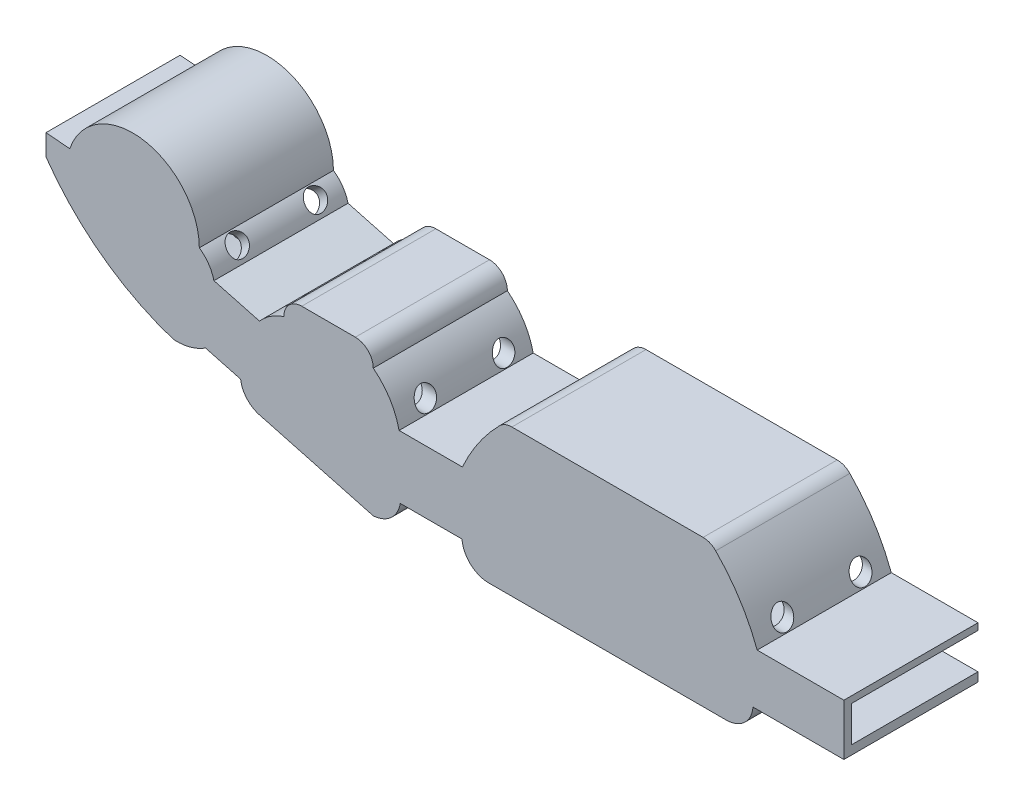
from build123d import *

# Parameters (mm, degrees)
WALLS_DEPTH                         = 16
BASE_DEPTH                          = 1
CUT_EXTRUDE2_REACH                  = 71.681
CUT_EXTRUDE2_END_RADIUS             = 7.978898039
SKETCH14_R                          = 1.4
CUT_EXTRUDE3_REACH                  = 103.113
CUT_EXTRUDE3_END_RADIUS             = 7.978898039
SKETCH15_R                          = 1.4
CUT_EXTRUDE4_REACH                  = 83.005
CUT_EXTRUDE4_END_RADIUS             = 33.443931457
SKETCH16_R                          = 1.4
CUT_EXTRUDE4_DIRECTION_2_REACH      = 83.005
CUT_EXTRUDE4_DIRECTION_2_END_RADIUS = 4.849339701
CUT_EXTRUDE5_REACH                  = 82.538
CUT_EXTRUDE5_END_RADIUS             = 6.135740623
SKETCH18_R                          = 1.4
CUT_EXTRUDE6_DEPTH                  = 1
CUT_EXTRUDE7_START                  = 4
SKETCH20_W                          = 0.5
SKETCH20_H                          = 5.968950485
CUT_EXTRUDE7_DEPTH                  = 10
CUT_EXTRUDE8_START                  = -1
SKETCH21_W                          = 1.2
SKETCH21_H                          = 4.8
CUT_EXTRUDE8_DEPTH                  = 17
BOSS_EXTRUDE7_DEPTH                 = 1


with BuildPart() as part:
    # Sketch1 → Walls (new body)
    with BuildSketch(Plane.XY):
        with BuildLine():
            Line((-97.602924667, 15.217392614), (-97.602924667, 12.385824824))
            ThreePointArc((-97.602924667, 12.385824824), (-90.083595642, 4.663063574), (-80.498331365, -0.266851135))
            ThreePointArc((-80.498331365, -0.266851135), (-78.251738027, -0.03182968), (-76.187199333, 0.884738205))
            Line((-76.187199333, 0.884738205), (-73.889967309, 0.268240269))
            Line((-73.889967309, 0.268240269), (-71.482418944, -0.377862773))
            ThreePointArc((-71.482418944, -0.377862773), (-70.590768518, -2.28542285), (-68.756284219, -3.319102342))
            Line((-68.756284219, -3.319102342), (-53.689410768, -7.362532125))
            ThreePointArc((-53.689410768, -7.362532125), (-51.300577468, -6.369383777), (-50.049451725, -4.104973799))
            Line((-50.049451725, -4.104973799), (-41.77845347, -4.104973799))
            ThreePointArc((-41.77845347, -4.104973799), (-40.630797432, -6.460513587), (-38.19022534, -7.414080542))
            Line((-38.19022534, -7.414080542), (-6.302454756, -7.414080542))
            ThreePointArc((-6.302454756, -7.414080542), (-3.861882663, -6.460513587), (-2.714226626, -4.104973799))
            Line((-2.714226626, -4.104973799), (9.481662569, -4.104973799))
            Line((9.481662569, -4.104973799), (9.481662569, 2.795026201))
            Line((9.481662569, 2.795026201), (-2.157765014, 2.795026201))
            ThreePointArc((-2.157765014, 2.795026201), (-4.475421171, 7.467506564), (-7.720187416, 11.551021571))
            ThreePointArc((-7.720187416, 11.551021571), (-8.494484922, 12.081481284), (-9.414311331, 12.268145448))
            Line((-9.414311331, 12.268145448), (-35.074048092, 12.268145448))
            ThreePointArc((-35.074048092, 12.268145448), (-35.993874501, 12.081481284), (-36.768172007, 11.551021571))
            ThreePointArc((-36.768172007, 11.551021571), (-39.567349429, 8.144207478), (-41.718065592, 4.295026201))
            Line((-41.718065592, 4.295026201), (-50.215351143, 4.295026201))
            ThreePointArc((-50.215351143, 4.295026201), (-51.466059783, 7.352239347), (-53.681234518, 9.802509784))
            ThreePointArc((-53.681234518, 9.802509784), (-54.384178243, 11.499566059), (-56.081234518, 12.202509784))
            Line((-56.081234518, 12.202509784), (-63.281234518, 12.202509784))
            ThreePointArc((-63.281234518, 12.202509784), (-64.978290793, 11.499566059), (-65.681234518, 9.802509784))
            ThreePointArc((-65.681234518, 9.802509784), (-67.462133389, 8.942613092), (-68.949921449, 7.63972791))
            Line((-68.949921449, 7.63972791), (-75.062434898, 9.280115945))
            ThreePointArc((-75.062434898, 9.280115945), (-75.782775767, 10.877592909), (-77.023853798, 12.114746473))
            ThreePointArc((-77.023853798, 12.114746473), (-84.520013622, 20.896236037), (-94.41446461, 14.945873803))
            Line((-94.41446461, 14.945873803), (-97.602924667, 15.217392614))
        make_face()
        with BuildLine():
            Line((-35.135188992, 10.657707985), (-34.831931662, 9.152027))
            Line((-34.831931662, 9.152027), (-34.528674333, 10.652027))
            Line((-34.528674333, 10.652027), (-33.854684343, 10.652027))
            Line((-33.854684343, 10.652027), (-33.554684343, 9.152027))
            Line((-33.554684343, 9.152027), (-33.254684343, 10.652027))
            Line((-33.254684343, 10.652027), (-32.554684343, 10.652027))
            Line((-32.554684343, 10.652027), (-32.254684343, 9.152027))
            Line((-32.254684343, 9.152027), (-31.954684343, 10.652027))
            Line((-31.954684343, 10.652027), (-31.254684343, 10.652027))
            Line((-31.254684343, 10.652027), (-30.954684343, 9.152027))
            Line((-30.954684343, 9.152027), (-30.654684343, 10.652027))
            Line((-30.654684343, 10.652027), (-29.954684343, 10.652027))
            Line((-29.954684343, 10.652027), (-29.654684343, 9.152027))
            Line((-29.654684343, 9.152027), (-29.354684343, 10.652027))
            Line((-29.354684343, 10.652027), (-28.654684343, 10.652027))
            Line((-28.654684343, 10.652027), (-28.354684343, 9.152027))
            Line((-28.354684343, 9.152027), (-28.054684343, 10.652027))
            Line((-28.054684343, 10.652027), (-27.354684343, 10.652027))
            Line((-27.354684343, 10.652027), (-27.054684343, 9.152027))
            Line((-27.054684343, 9.152027), (-26.754684343, 10.652027))
            Line((-26.754684343, 10.652027), (-26.054684343, 10.652027))
            Line((-26.054684343, 10.652027), (-25.754684343, 9.152027))
            Line((-25.754684343, 9.152027), (-25.454684343, 10.652027))
            Line((-25.454684343, 10.652027), (-24.754684343, 10.652027))
            Line((-24.754684343, 10.652027), (-24.454684343, 9.152027))
            Line((-24.454684343, 9.152027), (-24.154684343, 10.652027))
            Line((-24.154684343, 10.652027), (-23.454684343, 10.652027))
            Line((-23.454684343, 10.652027), (-23.154684343, 9.152027))
            Line((-23.154684343, 9.152027), (-22.854684343, 10.652027))
            Line((-22.854684343, 10.652027), (-22.154684343, 10.652027))
            Line((-22.154684343, 10.652027), (-21.854684343, 9.152027))
            Line((-21.854684343, 9.152027), (-21.554684343, 10.652027))
            Line((-21.554684343, 10.652027), (-20.854684343, 10.652027))
            Line((-20.854684343, 10.652027), (-20.554684343, 9.152027))
            Line((-20.554684343, 9.152027), (-20.254684343, 10.652027))
            Line((-20.254684343, 10.652027), (-19.554684343, 10.652027))
            Line((-19.554684343, 10.652027), (-19.254684343, 9.152027))
            Line((-19.254684343, 9.152027), (-18.954684343, 10.652027))
            Line((-18.954684343, 10.652027), (-18.254684343, 10.652027))
            Line((-18.254684343, 10.652027), (-17.954684343, 9.152027))
            Line((-17.954684343, 9.152027), (-17.654684343, 10.652027))
            Line((-17.654684343, 10.652027), (-16.954684343, 10.652027))
            Line((-16.954684343, 10.652027), (-16.654684343, 9.152027))
            Line((-16.654684343, 9.152027), (-16.354684343, 10.652027))
            Line((-16.354684343, 10.652027), (-15.654684343, 10.652027))
            Line((-15.654684343, 10.652027), (-15.354684343, 9.152027))
            Line((-15.354684343, 9.152027), (-15.054684343, 10.652027))
            Line((-15.054684343, 10.652027), (-14.354684343, 10.652027))
            Line((-14.354684343, 10.652027), (-14.054684343, 9.152027))
            Line((-14.054684343, 9.152027), (-13.754684343, 10.652027))
            Line((-13.754684343, 10.652027), (-13.080694354, 10.652027))
            Line((-13.080694354, 10.652027), (-12.780694354, 9.152027))
            Line((-12.780694354, 9.152027), (-12.480694354, 10.652027))
            Line((-12.480694354, 10.652027), (-11.780694354, 10.652027))
            Line((-11.780694354, 10.652027), (-11.480694354, 9.152027))
            Line((-11.480694354, 9.152027), (-11.180694354, 10.652027))
            Line((-11.180694354, 10.652027), (-10.506704364, 10.652027))
            Line((-10.506704364, 10.652027), (-10.206704364, 9.152027))
            Line((-10.206704364, 9.152027), (-9.906704364, 10.652027))
            Line((-9.906704364, 10.652027), (-9.353170431, 10.652027))
            ThreePointArc((-9.353170431, 10.652027), (-8.12308073, 9.896738229), (-7.34300907, 8.682213628))
            ThreePointArc((-7.34300907, 8.682213628), (-4.611558125, 5.76795929), (-3.634781843, 1.895026201))
            Line((-3.634781843, 1.895026201), (8.281662569, 1.895026201))
            Line((8.281662569, 1.895026201), (8.281662569, -2.904973799))
            Line((8.281662569, -2.904973799), (-3.718337431, -2.904973799))
            ThreePointArc((-3.718337431, -2.904973799), (-4.489094638, -5.239633694), (-6.746340048, -6.214080542))
            Line((-6.746340048, -6.214080542), (-37.746340048, -6.214080542))
            ThreePointArc((-37.746340048, -6.214080542), (-40.003585457, -5.239633694), (-40.774342664, -2.904973799))
            Line((-40.774342664, -2.904973799), (-51.800725155, -2.904973799))
            ThreePointArc((-51.800725155, -2.904973799), (-52.729784745, -4.937523747), (-54.747520344, -5.898332815))
            Line((-54.747520344, -5.898332815), (-67.30324822, -2.528807996))
            ThreePointArc((-67.30324822, -2.528807996), (-68.974427433, -1.501489359), (-69.597282071, 0.358692257))
            Line((-69.597282071, 0.358692257), (-77.437917333, 2.462848653))
            ThreePointArc((-77.437917333, 2.462848653), (-78.888444716, 1.000283853), (-80.940241825, 0.817926775))
            ThreePointArc((-80.940241825, 0.817926775), (-87.857363605, 4.137190402), (-93.56393849, 9.26545403))
            Line((-93.56393849, 9.26545403), (-96.861437096, 13.209190532))
            Line((-96.861437096, 13.209190532), (-96.861437096, 13.945331795))
            Line((-96.861437096, 13.945331795), (-96.47575976, 13.504674103))
            Line((-96.47575976, 13.504674103), (-94.817997325, 12.385824824))
            ThreePointArc((-94.817997325, 12.385824824), (-94.415427575, 12.562213326), (-94.008614676, 12.728582111))
            ThreePointArc((-94.008614676, 12.728582111), (-93.422599552, 14.777174035), (-92.319028879, 16.599884754))
            Line((-92.319028879, 16.599884754), (-92.019028879, 15.366152694))
            Line((-92.019028879, 15.366152694), (-91.719028879, 17.266152694))
            ThreePointArc((-91.719028879, 17.266152694), (-91.377286671, 17.586290744), (-91.017486201, 17.885990141))
            Line((-91.017486201, 17.885990141), (-90.717486201, 16.813922832))
            Line((-90.717486201, 16.813922832), (-90.417486201, 18.313922832))
            ThreePointArc((-90.417486201, 18.313922832), (-90.073465252, 18.524190844), (-89.719335551, 18.716947696))
            Line((-89.719335551, 18.716947696), (-89.419335551, 17.693779836))
            Line((-89.419335551, 17.693779836), (-89.119335551, 18.993779836))
            ThreePointArc((-89.119335551, 18.993779836), (-88.772503114, 19.127528905), (-88.41985912, 19.245103414))
            Line((-88.41985912, 19.245103414), (-88.11985912, 18.147652874))
            Line((-88.11985912, 18.147652874), (-87.81985912, 19.404765549))
            ThreePointArc((-87.81985912, 19.404765549), (-87.472338401, 19.474995797), (-87.122059311, 19.529836442))
            Line((-87.122059311, 19.529836442), (-86.822059311, 18.396857922))
            Line((-86.822059311, 18.396857922), (-86.522059311, 19.58746676))
            ThreePointArc((-86.522059311, 19.58746676), (-86.171544793, 19.600247924), (-85.82080637, 19.597729108))
            Line((-85.82080637, 19.597729108), (-85.52080637, 18.457829923))
            Line((-85.52080637, 18.457829923), (-85.22080637, 19.557829923))
            ThreePointArc((-85.22080637, 19.557829923), (-84.869658801, 19.513414143), (-84.52080637, 19.453586402))
            Line((-84.52080637, 19.453586402), (-84.22080637, 18.262977563))
            Line((-84.22080637, 18.262977563), (-83.92080637, 19.312977563))
            ThreePointArc((-83.92080637, 19.312977563), (-83.568200749, 19.207208521), (-83.22080637, 19.085409669))
            Line((-83.22080637, 19.085409669), (-82.92080637, 17.831277439))
            Line((-82.92080637, 17.831277439), (-82.62080637, 18.831277439))
            ThreePointArc((-82.62080637, 18.831277439), (-82.2661907, 18.652985458), (-81.92080637, 18.457409466))
            Line((-81.92080637, 18.457409466), (-81.62080637, 16.960277091))
            Line((-81.62080637, 16.960277091), (-81.32080637, 18.060277091))
            ThreePointArc((-81.32080637, 18.060277091), (-80.96274655, 17.783767154), (-80.62080637, 17.487555249))
            Line((-80.62080637, 17.487555249), (-80.32080637, 15.675519278))
            Line((-80.32080637, 15.675519278), (-80.02080637, 16.875519278))
            ThreePointArc((-80.02080637, 16.875519278), (-79.654234956, 16.427873033), (-79.32080637, 15.955023014))
            Line((-79.32080637, 15.955023014), (-79.02080637, 12.857560784))
            Line((-79.02080637, 12.857560784), (-78.72080637, 14.857560784))
            ThreePointArc((-78.72080637, 14.857560784), (-78.159606325, 13.084494169), (-78.02080637, 11.229920016))
            ThreePointArc((-78.02080637, 11.229920016), (-76.848832526, 9.985898204), (-76.295916922, 8.368679203))
            Line((-76.295916922, 8.368679203), (-68.569315152, 6.295125468))
            ThreePointArc((-68.569315152, 6.295125468), (-67.180506607, 7.752660176), (-65.394693914, 8.682213628))
            ThreePointArc((-65.394693914, 8.682213628), (-64.808907476, 10.096427191), (-63.394693914, 10.682213628))
            Line((-63.394693914, 10.682213628), (-63.310840233, 10.682178618))
            Line((-63.310840233, 10.682178618), (-63.010840233, 9.182178618))
            Line((-63.010840233, 9.182178618), (-62.710840233, 10.682178618))
            Line((-62.710840233, 10.682178618), (-62.010840233, 10.682178618))
            Line((-62.010840233, 10.682178618), (-61.710840233, 9.182178618))
            Line((-61.710840233, 9.182178618), (-61.410840233, 10.682178618))
            Line((-61.410840233, 10.682178618), (-60.710840233, 10.682178618))
            Line((-60.710840233, 10.682178618), (-60.410840233, 9.182178618))
            Line((-60.410840233, 9.182178618), (-60.110840233, 10.682178618))
            Line((-60.110840233, 10.682178618), (-59.436850244, 10.682178618))
            Line((-59.436850244, 10.682178618), (-59.136850244, 9.182178618))
            Line((-59.136850244, 9.182178618), (-58.836850244, 10.682178618))
            Line((-58.836850244, 10.682178618), (-58.136850244, 10.682178618))
            Line((-58.136850244, 10.682178618), (-57.836850244, 9.182178618))
            Line((-57.836850244, 9.182178618), (-57.536850244, 10.682178618))
            Line((-57.536850244, 10.682178618), (-57.394693914, 10.682213628))
            ThreePointArc((-57.394693914, 10.682213628), (-55.980480351, 10.096427191), (-55.394693914, 8.682213628))
            ThreePointArc((-55.394693914, 8.682213628), (-52.971538613, 6.284887251), (-51.770022133, 3.095026201))
            Line((-51.770022133, 3.095026201), (-40.770022133, 3.095026201))
            ThreePointArc((-40.770022133, 3.095026201), (-39.568505653, 6.284887251), (-37.145350353, 8.682213628))
            ThreePointArc((-37.145350353, 8.682213628), (-37.020286062, 9.372290059), (-36.66100173, 9.974586769))
            ThreePointArc((-36.66100173, 9.974586769), (-35.973167424, 10.483827589), (-35.135188992, 10.657707985))
        make_face(mode=Mode.SUBTRACT)
    extrude(amount=WALLS_DEPTH)

    # Sketch2 → Base (add)
    with BuildSketch(Plane(origin=(0, 0, 0), x_dir=(-1, 0, 0), z_dir=(0, 0, -1))):
        with BuildLine():
            Line((75.062434898, 9.280115945), (68.949921449, 7.63972791))
            ThreePointArc((68.949921449, 7.63972791), (67.462133389, 8.942613092), (65.681234518, 9.802509784))
            ThreePointArc((65.681234518, 9.802509784), (64.978290793, 11.499566059), (63.281234518, 12.202509784))
            Line((63.281234518, 12.202509784), (56.081234518, 12.202509784))
            ThreePointArc((56.081234518, 12.202509784), (54.384178243, 11.499566059), (53.681234518, 9.802509784))
            ThreePointArc((53.681234518, 9.802509784), (51.466059783, 7.352239347), (50.215351143, 4.295026201))
            Line((50.215351143, 4.295026201), (41.718065592, 4.295026201))
            ThreePointArc((41.718065592, 4.295026201), (39.567349429, 8.144207478), (36.768172007, 11.551021571))
            ThreePointArc((36.768172007, 11.551021571), (35.993874501, 12.081481284), (35.074048092, 12.268145448))
            Line((35.074048092, 12.268145448), (9.414311331, 12.268145448))
            ThreePointArc((9.414311331, 12.268145448), (8.494484922, 12.081481284), (7.720187416, 11.551021571))
            ThreePointArc((7.720187416, 11.551021571), (4.475421171, 7.467506564), (2.157765014, 2.795026201))
            Line((2.157765014, 2.795026201), (-9.481662569, 2.795026201))
            Line((-9.481662569, 2.795026201), (-9.481662569, -4.104973799))
            Line((-9.481662569, -4.104973799), (2.714226626, -4.104973799))
            ThreePointArc((2.714226626, -4.104973799), (3.861882663, -6.460513587), (6.302454756, -7.414080542))
            Line((6.302454756, -7.414080542), (38.19022534, -7.414080542))
            ThreePointArc((38.19022534, -7.414080542), (40.630797432, -6.460513587), (41.77845347, -4.104973799))
            Line((41.77845347, -4.104973799), (50.049451725, -4.104973799))
            ThreePointArc((50.049451725, -4.104973799), (51.300577468, -6.369383777), (53.689410768, -7.362532125))
            Line((53.689410768, -7.362532125), (68.756284219, -3.319102342))
            ThreePointArc((68.756284219, -3.319102342), (70.590768518, -2.28542285), (71.482418944, -0.377862773))
            Line((71.482418944, -0.377862773), (76.187199333, 0.884738205))
            ThreePointArc((76.187199333, 0.884738205), (78.251738027, -0.03182968), (80.498331365, -0.266851135))
            ThreePointArc((80.498331365, -0.266851135), (90.083595642, 4.663063574), (97.602924667, 12.385824824))
            Line((97.602924667, 12.385824824), (97.602924667, 15.217392614))
            Line((97.602924667, 15.217392614), (94.41446461, 14.945873803))
            ThreePointArc((94.41446461, 14.945873803), (84.520013622, 20.896236037), (77.023853798, 12.114746473))
            ThreePointArc((77.023853798, 12.114746473), (75.782775767, 10.877592909), (75.062434898, 9.280115945))
        make_face()
    extrude(amount=BASE_DEPTH)

    # Cut-Extrude2: up to this cylinder (the profile starts outside it)
    cut_extrude2_end = Plane(origin=(-32.874820049, 1.942377959, 7.75), z_dir=(0, 0, -1)) * Cylinder(CUT_EXTRUDE2_END_RADIUS, 170.819796077, mode=Mode.PRIVATE)
    # Sketch14 → Cut-Extrude2 (cut, up to the surface)
    with BuildSketch(Plane(origin=(-55, 0, 0), x_dir=(0, 0, -1), z_dir=(1, 0, 0)), mode=Mode.PRIVATE) as cut_extrude2_sk1:
        with Locations(Location((-13, 5.771124661, 0), (0, 0, 180))):
            Circle(SKETCH14_R)
    cut_extrude2_tool1 = extrude(cut_extrude2_sk1.sketch, amount=CUT_EXTRUDE2_REACH, mode=Mode.PRIVATE) - cut_extrude2_end
    add(cut_extrude2_tool1.solids().sort_by_distance((-55, 5.771125, 13))[0], mode=Mode.SUBTRACT)
    # Sketch14 → Cut-Extrude2 (cut, up to the surface)
    with BuildSketch(Plane(origin=(-55, 0, 0), x_dir=(0, 0, -1), z_dir=(1, 0, 0)), mode=Mode.PRIVATE) as cut_extrude2_sk2:
        with Locations(Location((-2.5, 5.771124661, 0), (0, 0, 180))):
            Circle(SKETCH14_R)
    cut_extrude2_tool2 = extrude(cut_extrude2_sk2.sketch, amount=CUT_EXTRUDE2_REACH, mode=Mode.PRIVATE) - cut_extrude2_end
    add(cut_extrude2_tool2.solids().sort_by_distance((-55, 5.771125, 2.5))[0], mode=Mode.SUBTRACT)

    # Cut-Extrude3: up to this cylinder (the profile starts outside it)
    cut_extrude3_end = Plane(origin=(-11.613539373, 1.942377959, 7.75), z_dir=(0, 0, -1)) * Cylinder(CUT_EXTRUDE3_END_RADIUS, 233.683796077, mode=Mode.PRIVATE)
    # Sketch15 → Cut-Extrude3 (cut, up to the surface)
    with BuildSketch(Plane(origin=(0, 0, 0), x_dir=(0, 0, -1), z_dir=(1, 0, 0)), mode=Mode.PRIVATE) as cut_extrude3_sk1:
        with Locations((-13, 4.295026201)):
            Circle(SKETCH15_R)
    cut_extrude3_tool1 = extrude(cut_extrude3_sk1.sketch, amount=-CUT_EXTRUDE3_REACH, mode=Mode.PRIVATE) - cut_extrude3_end
    add(cut_extrude3_tool1.solids().sort_by_distance((0, 4.295026, 13))[0], mode=Mode.SUBTRACT)
    # Sketch15 → Cut-Extrude3 (cut, up to the surface)
    with BuildSketch(Plane(origin=(0, 0, 0), x_dir=(0, 0, -1), z_dir=(1, 0, 0)), mode=Mode.PRIVATE) as cut_extrude3_sk2:
        with Locations((-2.5, 4.295026201)):
            Circle(SKETCH15_R)
    cut_extrude3_tool2 = extrude(cut_extrude3_sk2.sketch, amount=-CUT_EXTRUDE3_REACH, mode=Mode.PRIVATE) - cut_extrude3_end
    add(cut_extrude3_tool2.solids().sort_by_distance((0, 4.295026, 2.5))[0], mode=Mode.SUBTRACT)

    # Cut-Extrude4: up to this cylinder (the profile starts inside it)
    cut_extrude4_end = Plane(origin=(-70.194504588, 31.550246549, 7.75), z_dir=(0, 0, -1)) * Cylinder(CUT_EXTRUDE4_END_RADIUS, 244.397862914, mode=Mode.PRIVATE)
    # Sketch16 → Cut-Extrude4 (cut, up to the surface)
    with BuildSketch(Plane(origin=(-39.508218545, -33.125189119, 0), x_dir=(0, 0, -1), z_dir=(0.7662940611199173, 0.6424900091770647, 0)), mode=Mode.PRIVATE) as cut_extrude4_sk1:
        with Locations(Location((-2.5, 57.212258814, 0), (0, 0, 90))):
            Circle(SKETCH16_R)
    cut_extrude4_tool1 = extrude(cut_extrude4_sk1.sketch, amount=-CUT_EXTRUDE4_REACH, mode=Mode.PRIVATE) & cut_extrude4_end
    add(cut_extrude4_tool1.solids().sort_by_distance((-76.266523, 10.716225, 2.5))[0], mode=Mode.SUBTRACT)
    # Sketch16 → Cut-Extrude4 (cut, up to the surface)
    with BuildSketch(Plane(origin=(-39.508218545, -33.125189119, 0), x_dir=(0, 0, -1), z_dir=(0.7662940611199173, 0.6424900091770647, 0)), mode=Mode.PRIVATE) as cut_extrude4_sk2:
        with Locations(Location((-13, 57.212258814, 0), (0, 0, 90))):
            Circle(SKETCH16_R)
    cut_extrude4_tool2 = extrude(cut_extrude4_sk2.sketch, amount=-CUT_EXTRUDE4_REACH, mode=Mode.PRIVATE) & cut_extrude4_end
    add(cut_extrude4_tool2.solids().sort_by_distance((-76.266523, 10.716225, 13))[0], mode=Mode.SUBTRACT)

    # Cut-Extrude4 direction 2: up to this cylinder (the profile starts inside it)
    cut_extrude4_direction_2_end = Plane(origin=(-79.77053487, 8.118268196, 7.75), z_dir=(0, 0, -1)) * Cylinder(CUT_EXTRUDE4_DIRECTION_2_END_RADIUS, 187.208679402, mode=Mode.PRIVATE)
    # Sketch16 → Cut-Extrude4 direction 2 (cut, up to the surface)
    with BuildSketch(Plane(origin=(-39.508218545, -33.125189119, 0), x_dir=(0, 0, -1), z_dir=(0.7662940611199173, 0.6424900091770647, 0)), mode=Mode.PRIVATE) as cut_extrude4_direction_2_sk1:
        with Locations(Location((-2.5, 57.212258814, 0), (0, 0, 90))):
            Circle(SKETCH16_R)
    cut_extrude4_direction_2_tool1 = extrude(cut_extrude4_direction_2_sk1.sketch, amount=CUT_EXTRUDE4_DIRECTION_2_REACH, mode=Mode.PRIVATE) & cut_extrude4_direction_2_end
    add(cut_extrude4_direction_2_tool1.solids().sort_by_distance((-76.266523, 10.716225, 2.5))[0], mode=Mode.SUBTRACT)
    # Sketch16 → Cut-Extrude4 direction 2 (cut, up to the surface)
    with BuildSketch(Plane(origin=(-39.508218545, -33.125189119, 0), x_dir=(0, 0, -1), z_dir=(0.7662940611199173, 0.6424900091770647, 0)), mode=Mode.PRIVATE) as cut_extrude4_direction_2_sk2:
        with Locations(Location((-13, 57.212258814, 0), (0, 0, 90))):
            Circle(SKETCH16_R)
    cut_extrude4_direction_2_tool2 = extrude(cut_extrude4_direction_2_sk2.sketch, amount=CUT_EXTRUDE4_DIRECTION_2_REACH, mode=Mode.PRIVATE) & cut_extrude4_direction_2_end
    add(cut_extrude4_direction_2_tool2.solids().sort_by_distance((-76.266523, 10.716225, 13))[0], mode=Mode.SUBTRACT)

    # Cut-Extrude5: up to this cylinder (the profile starts outside it)
    cut_extrude5_end = Plane(origin=(-63.493012284, 2.84861097, 7.75), z_dir=(0, 0, -1)) * Cylinder(CUT_EXTRUDE5_END_RADIUS, 188.847481246, mode=Mode.PRIVATE)
    # Sketch18 → Cut-Extrude5 (cut, up to the surface)
    with BuildSketch(Plane(origin=(-63.324723417, 23.076173835, 0), x_dir=(0, 0, -1), z_dir=(-0.939559700184993, 0.3423851191104633, 0)), mode=Mode.PRIVATE) as cut_extrude5_sk1:
        with Locations(Location((-2.5, 14.855442721, 0), (0, 0, 90))):
            Circle(SKETCH18_R)
    cut_extrude5_tool1 = extrude(cut_extrude5_sk1.sketch, amount=-CUT_EXTRUDE5_REACH, mode=Mode.PRIVATE) - cut_extrude5_end
    add(cut_extrude5_tool1.solids().sort_by_distance((-68.411006, 9.118599, 2.5))[0], mode=Mode.SUBTRACT)
    # Sketch18 → Cut-Extrude5 (cut, up to the surface)
    with BuildSketch(Plane(origin=(-63.324723417, 23.076173835, 0), x_dir=(0, 0, -1), z_dir=(-0.939559700184993, 0.3423851191104633, 0)), mode=Mode.PRIVATE) as cut_extrude5_sk2:
        with Locations(Location((-13, 14.865403278, 0), (0, 0, 90))):
            Circle(SKETCH18_R)
    cut_extrude5_tool2 = extrude(cut_extrude5_sk2.sketch, amount=-CUT_EXTRUDE5_REACH, mode=Mode.PRIVATE) - cut_extrude5_end
    add(cut_extrude5_tool2.solids().sort_by_distance((-68.414416, 9.10924, 13))[0], mode=Mode.SUBTRACT)

    # Sketch19 → Cut-Extrude6 (cut)
    with BuildSketch(Plane.XY):
        with BuildLine():
            Line((-34.831931662, 9.152027), (-35.135188992, 10.657707985))
            ThreePointArc((-35.135188992, 10.657707985), (-35.973167424, 10.483827589), (-36.66100173, 9.974586769))
            ThreePointArc((-36.66100173, 9.974586769), (-37.020286062, 9.372290059), (-37.145350353, 8.682213628))
            ThreePointArc((-37.145350353, 8.682213628), (-39.568505653, 6.284887251), (-40.770022133, 3.095026201))
            Line((-40.770022133, 3.095026201), (-51.770022133, 3.095026201))
            ThreePointArc((-51.770022133, 3.095026201), (-52.971538613, 6.284887251), (-55.394693914, 8.682213628))
            ThreePointArc((-55.394693914, 8.682213628), (-55.980480351, 10.096427191), (-57.394693914, 10.682213628))
            Line((-57.394693914, 10.682213628), (-57.536850244, 10.682178618))
            Line((-57.536850244, 10.682178618), (-57.836850244, 9.182178618))
            Line((-57.836850244, 9.182178618), (-58.136850244, 10.682178618))
            Line((-58.136850244, 10.682178618), (-58.836850244, 10.682178618))
            Line((-58.836850244, 10.682178618), (-59.136850244, 9.182178618))
            Line((-59.136850244, 9.182178618), (-59.436850244, 10.682178618))
            Line((-59.436850244, 10.682178618), (-60.110840233, 10.682178618))
            Line((-60.110840233, 10.682178618), (-60.410840233, 9.182178618))
            Line((-60.410840233, 9.182178618), (-60.710840233, 10.682178618))
            Line((-60.710840233, 10.682178618), (-61.410840233, 10.682178618))
            Line((-61.410840233, 10.682178618), (-61.710840233, 9.182178618))
            Line((-61.710840233, 9.182178618), (-62.010840233, 10.682178618))
            Line((-62.010840233, 10.682178618), (-62.710840233, 10.682178618))
            Line((-62.710840233, 10.682178618), (-63.010840233, 9.182178618))
            Line((-63.010840233, 9.182178618), (-63.310840233, 10.682178618))
            Line((-63.310840233, 10.682178618), (-63.394693914, 10.682213628))
            ThreePointArc((-63.394693914, 10.682213628), (-64.808907476, 10.096427191), (-65.394693914, 8.682213628))
            ThreePointArc((-65.394693914, 8.682213628), (-67.180506607, 7.752660176), (-68.569315152, 6.295125468))
            Line((-68.569315152, 6.295125468), (-76.295916922, 8.368679203))
            ThreePointArc((-76.295916922, 8.368679203), (-76.848832526, 9.985898204), (-78.02080637, 11.229920016))
            ThreePointArc((-78.02080637, 11.229920016), (-78.159606325, 13.084494169), (-78.72080637, 14.857560784))
            Line((-78.72080637, 14.857560784), (-79.02080637, 12.857560784))
            Line((-79.02080637, 12.857560784), (-79.32080637, 15.955023014))
            ThreePointArc((-79.32080637, 15.955023014), (-79.654234956, 16.427873033), (-80.02080637, 16.875519278))
            Line((-80.02080637, 16.875519278), (-80.32080637, 15.675519278))
            Line((-80.32080637, 15.675519278), (-80.62080637, 17.487555249))
            ThreePointArc((-80.62080637, 17.487555249), (-80.96274655, 17.783767154), (-81.32080637, 18.060277091))
            Line((-81.32080637, 18.060277091), (-81.62080637, 16.960277091))
            Line((-81.62080637, 16.960277091), (-81.92080637, 18.457409466))
            ThreePointArc((-81.92080637, 18.457409466), (-82.2661907, 18.652985458), (-82.62080637, 18.831277439))
            Line((-82.62080637, 18.831277439), (-82.92080637, 17.831277439))
            Line((-82.92080637, 17.831277439), (-83.22080637, 19.085409669))
            ThreePointArc((-83.22080637, 19.085409669), (-83.568200749, 19.207208521), (-83.92080637, 19.312977563))
            Line((-83.92080637, 19.312977563), (-84.22080637, 18.262977563))
            Line((-84.22080637, 18.262977563), (-84.52080637, 19.453586402))
            ThreePointArc((-84.52080637, 19.453586402), (-84.869658801, 19.513414143), (-85.22080637, 19.557829923))
            Line((-85.22080637, 19.557829923), (-85.52080637, 18.457829923))
            Line((-85.52080637, 18.457829923), (-85.82080637, 19.597729108))
            ThreePointArc((-85.82080637, 19.597729108), (-86.171544793, 19.600247924), (-86.522059311, 19.58746676))
            Line((-86.522059311, 19.58746676), (-86.822059311, 18.396857922))
            Line((-86.822059311, 18.396857922), (-87.122059311, 19.529836442))
            ThreePointArc((-87.122059311, 19.529836442), (-87.472338401, 19.474995797), (-87.81985912, 19.404765549))
            Line((-87.81985912, 19.404765549), (-88.11985912, 18.147652874))
            Line((-88.11985912, 18.147652874), (-88.41985912, 19.245103414))
            ThreePointArc((-88.41985912, 19.245103414), (-88.772503114, 19.127528905), (-89.119335551, 18.993779836))
            Line((-89.119335551, 18.993779836), (-89.419335551, 17.693779836))
            Line((-89.419335551, 17.693779836), (-89.719335551, 18.716947696))
            ThreePointArc((-89.719335551, 18.716947696), (-90.073465252, 18.524190844), (-90.417486201, 18.313922832))
            Line((-90.417486201, 18.313922832), (-90.717486201, 16.813922832))
            Line((-90.717486201, 16.813922832), (-91.017486201, 17.885990141))
            ThreePointArc((-91.017486201, 17.885990141), (-91.377286671, 17.586290744), (-91.719028879, 17.266152694))
            Line((-91.719028879, 17.266152694), (-92.019028879, 15.366152694))
            Line((-92.019028879, 15.366152694), (-92.319028879, 16.599884754))
            ThreePointArc((-92.319028879, 16.599884754), (-93.422599552, 14.777174035), (-94.008614676, 12.728582111))
            ThreePointArc((-94.008614676, 12.728582111), (-94.415427575, 12.562213326), (-94.817997325, 12.385824824))
            Line((-94.817997325, 12.385824824), (-96.47575976, 13.504674103))
            Line((-96.47575976, 13.504674103), (-96.861437096, 13.945331795))
            Line((-96.861437096, 13.945331795), (-96.861437096, 13.209190532))
            Line((-96.861437096, 13.209190532), (-93.56393849, 9.26545403))
            ThreePointArc((-93.56393849, 9.26545403), (-87.857363605, 4.137190402), (-80.940241825, 0.817926775))
            ThreePointArc((-80.940241825, 0.817926775), (-78.888444716, 1.000283853), (-77.437917333, 2.462848653))
            Line((-77.437917333, 2.462848653), (-69.597282071, 0.358692257))
            ThreePointArc((-69.597282071, 0.358692257), (-68.974427433, -1.501489359), (-67.30324822, -2.528807996))
            Line((-67.30324822, -2.528807996), (-54.747520344, -5.898332815))
            ThreePointArc((-54.747520344, -5.898332815), (-52.729784745, -4.937523747), (-51.800725155, -2.904973799))
            Line((-51.800725155, -2.904973799), (-40.774342664, -2.904973799))
            ThreePointArc((-40.774342664, -2.904973799), (-40.003585457, -5.239633694), (-37.746340048, -6.214080542))
            Line((-37.746340048, -6.214080542), (-6.746340048, -6.214080542))
            ThreePointArc((-6.746340048, -6.214080542), (-4.489094638, -5.239633694), (-3.718337431, -2.904973799))
            Line((-3.718337431, -2.904973799), (8.281662569, -2.904973799))
            Line((8.281662569, -2.904973799), (8.281662569, 1.895026201))
            Line((8.281662569, 1.895026201), (-3.634781843, 1.895026201))
            ThreePointArc((-3.634781843, 1.895026201), (-4.611558125, 5.76795929), (-7.34300907, 8.682213628))
            ThreePointArc((-7.34300907, 8.682213628), (-8.12308073, 9.896738229), (-9.353170431, 10.652027))
            Line((-9.353170431, 10.652027), (-9.906704364, 10.652027))
            Line((-9.906704364, 10.652027), (-10.206704364, 9.152027))
            Line((-10.206704364, 9.152027), (-10.506704364, 10.652027))
            Line((-10.506704364, 10.652027), (-11.180694354, 10.652027))
            Line((-11.180694354, 10.652027), (-11.480694354, 9.152027))
            Line((-11.480694354, 9.152027), (-11.780694354, 10.652027))
            Line((-11.780694354, 10.652027), (-12.480694354, 10.652027))
            Line((-12.480694354, 10.652027), (-12.780694354, 9.152027))
            Line((-12.780694354, 9.152027), (-13.080694354, 10.652027))
            Line((-13.080694354, 10.652027), (-13.754684343, 10.652027))
            Line((-13.754684343, 10.652027), (-14.054684343, 9.152027))
            Line((-14.054684343, 9.152027), (-14.354684343, 10.652027))
            Line((-14.354684343, 10.652027), (-15.054684343, 10.652027))
            Line((-15.054684343, 10.652027), (-15.354684343, 9.152027))
            Line((-15.354684343, 9.152027), (-15.654684343, 10.652027))
            Line((-15.654684343, 10.652027), (-16.354684343, 10.652027))
            Line((-16.354684343, 10.652027), (-16.654684343, 9.152027))
            Line((-16.654684343, 9.152027), (-16.954684343, 10.652027))
            Line((-16.954684343, 10.652027), (-17.654684343, 10.652027))
            Line((-17.654684343, 10.652027), (-17.954684343, 9.152027))
            Line((-17.954684343, 9.152027), (-18.254684343, 10.652027))
            Line((-18.254684343, 10.652027), (-18.954684343, 10.652027))
            Line((-18.954684343, 10.652027), (-19.254684343, 9.152027))
            Line((-19.254684343, 9.152027), (-19.554684343, 10.652027))
            Line((-19.554684343, 10.652027), (-20.254684343, 10.652027))
            Line((-20.254684343, 10.652027), (-20.554684343, 9.152027))
            Line((-20.554684343, 9.152027), (-20.854684343, 10.652027))
            Line((-20.854684343, 10.652027), (-21.554684343, 10.652027))
            Line((-21.554684343, 10.652027), (-21.854684343, 9.152027))
            Line((-21.854684343, 9.152027), (-22.154684343, 10.652027))
            Line((-22.154684343, 10.652027), (-22.854684343, 10.652027))
            Line((-22.854684343, 10.652027), (-23.154684343, 9.152027))
            Line((-23.154684343, 9.152027), (-23.454684343, 10.652027))
            Line((-23.454684343, 10.652027), (-24.154684343, 10.652027))
            Line((-24.154684343, 10.652027), (-24.454684343, 9.152027))
            Line((-24.454684343, 9.152027), (-24.754684343, 10.652027))
            Line((-24.754684343, 10.652027), (-25.454684343, 10.652027))
            Line((-25.454684343, 10.652027), (-25.754684343, 9.152027))
            Line((-25.754684343, 9.152027), (-26.054684343, 10.652027))
            Line((-26.054684343, 10.652027), (-26.754684343, 10.652027))
            Line((-26.754684343, 10.652027), (-27.054684343, 9.152027))
            Line((-27.054684343, 9.152027), (-27.354684343, 10.652027))
            Line((-27.354684343, 10.652027), (-28.054684343, 10.652027))
            Line((-28.054684343, 10.652027), (-28.354684343, 9.152027))
            Line((-28.354684343, 9.152027), (-28.654684343, 10.652027))
            Line((-28.654684343, 10.652027), (-29.354684343, 10.652027))
            Line((-29.354684343, 10.652027), (-29.654684343, 9.152027))
            Line((-29.654684343, 9.152027), (-29.954684343, 10.652027))
            Line((-29.954684343, 10.652027), (-30.654684343, 10.652027))
            Line((-30.654684343, 10.652027), (-30.954684343, 9.152027))
            Line((-30.954684343, 9.152027), (-31.254684343, 10.652027))
            Line((-31.254684343, 10.652027), (-31.954684343, 10.652027))
            Line((-31.954684343, 10.652027), (-32.254684343, 9.152027))
            Line((-32.254684343, 9.152027), (-32.554684343, 10.652027))
            Line((-32.554684343, 10.652027), (-33.254684343, 10.652027))
            Line((-33.254684343, 10.652027), (-33.554684343, 9.152027))
            Line((-33.554684343, 9.152027), (-33.854684343, 10.652027))
            Line((-33.854684343, 10.652027), (-34.528674333, 10.652027))
            Line((-34.528674333, 10.652027), (-34.831931662, 9.152027))
        make_face()
    extrude(amount=-CUT_EXTRUDE6_DEPTH, mode=Mode.SUBTRACT)

    # Sketch20 → Cut-Extrude7 (cut)
    with BuildSketch(Plane.XY.offset(CUT_EXTRUDE7_START)):
        Polygon((-93.79820137, 5.88509044), (-91.319234649, 8.302207551), (-90.984964501, 7.929796316), (-93.449142081, 5.527099361), align=None)
        Polygon((-64.188524134, -5.994272413), (-63.100989198, -1.941833733), (-62.618076588, -2.071430841), (-63.705611523, -6.123869521), align=None)
        Polygon((-82.077715773, 2.057048706), (-83.109297412, -0.67837574), (-82.641459615, -0.854806451), (-81.609877976, 1.880617994), align=None)
        with Locations((-24.497959011, -7.165975116)):
            Rectangle(SKETCH20_W, SKETCH20_H)
    extrude(amount=CUT_EXTRUDE7_DEPTH, mode=Mode.SUBTRACT)

    # Sketch21 → Cut-Extrude8 (cut)
    with BuildSketch(Plane.XY.offset(CUT_EXTRUDE8_START)):
        with Locations((8.881662569, -0.504973799)):
            Rectangle(SKETCH21_W, SKETCH21_H)
    extrude(amount=CUT_EXTRUDE8_DEPTH, mode=Mode.SUBTRACT)

    # Sketch22 → Boss-Extrude7 (add)
    with BuildSketch(Plane.XY.offset(16)):
        with BuildLine():
            Line((-50.215351143, 4.295026201), (-41.718065592, 4.295026201))
            ThreePointArc((-41.718065592, 4.295026201), (-39.567349429, 8.144207478), (-36.768172007, 11.551021571))
            ThreePointArc((-36.768172007, 11.551021571), (-35.993874501, 12.081481284), (-35.074048092, 12.268145448))
            Line((-35.074048092, 12.268145448), (-9.414311331, 12.268145448))
            ThreePointArc((-9.414311331, 12.268145448), (-8.494484922, 12.081481284), (-7.720187416, 11.551021571))
            ThreePointArc((-7.720187416, 11.551021571), (-4.475421171, 7.467506564), (-2.157765014, 2.795026201))
            Line((-2.157765014, 2.795026201), (9.481662569, 2.795026201))
            Line((9.481662569, 2.795026201), (9.481662569, -4.104973799))
            Line((9.481662569, -4.104973799), (-2.714226626, -4.104973799))
            ThreePointArc((-2.714226626, -4.104973799), (-3.861882663, -6.460513587), (-6.302454756, -7.414080542))
            Line((-6.302454756, -7.414080542), (-38.19022534, -7.414080542))
            ThreePointArc((-38.19022534, -7.414080542), (-40.630797432, -6.460513587), (-41.77845347, -4.104973799))
            Line((-41.77845347, -4.104973799), (-50.049451725, -4.104973799))
            ThreePointArc((-50.049451725, -4.104973799), (-51.300577468, -6.369383777), (-53.689410768, -7.362532125))
            Line((-53.689410768, -7.362532125), (-68.756284219, -3.319102342))
            ThreePointArc((-68.756284219, -3.319102342), (-70.590768518, -2.28542285), (-71.482418944, -0.377862773))
            Line((-71.482418944, -0.377862773), (-76.187199333, 0.884738205))
            ThreePointArc((-76.187199333, 0.884738205), (-78.251738027, -0.03182968), (-80.498331365, -0.266851135))
            ThreePointArc((-80.498331365, -0.266851135), (-90.083595642, 4.663063574), (-97.602924667, 12.385824824))
            Line((-97.602924667, 12.385824824), (-97.602924667, 15.217392614))
            Line((-97.602924667, 15.217392614), (-94.41446461, 14.945873803))
            ThreePointArc((-94.41446461, 14.945873803), (-84.520013622, 20.896236037), (-77.023853798, 12.114746473))
            ThreePointArc((-77.023853798, 12.114746473), (-75.782775767, 10.877592909), (-75.062434898, 9.280115945))
            Line((-75.062434898, 9.280115945), (-68.949921449, 7.63972791))
            ThreePointArc((-68.949921449, 7.63972791), (-67.462133389, 8.942613092), (-65.681234518, 9.802509784))
            ThreePointArc((-65.681234518, 9.802509784), (-64.978290793, 11.499566059), (-63.281234518, 12.202509784))
            Line((-63.281234518, 12.202509784), (-56.081234518, 12.202509784))
            ThreePointArc((-56.081234518, 12.202509784), (-54.384178243, 11.499566059), (-53.681234518, 9.802509784))
            ThreePointArc((-53.681234518, 9.802509784), (-51.466059783, 7.352239347), (-50.215351143, 4.295026201))
        make_face()
    extrude(amount=BOSS_EXTRUDE7_DEPTH)


solid = part.part
